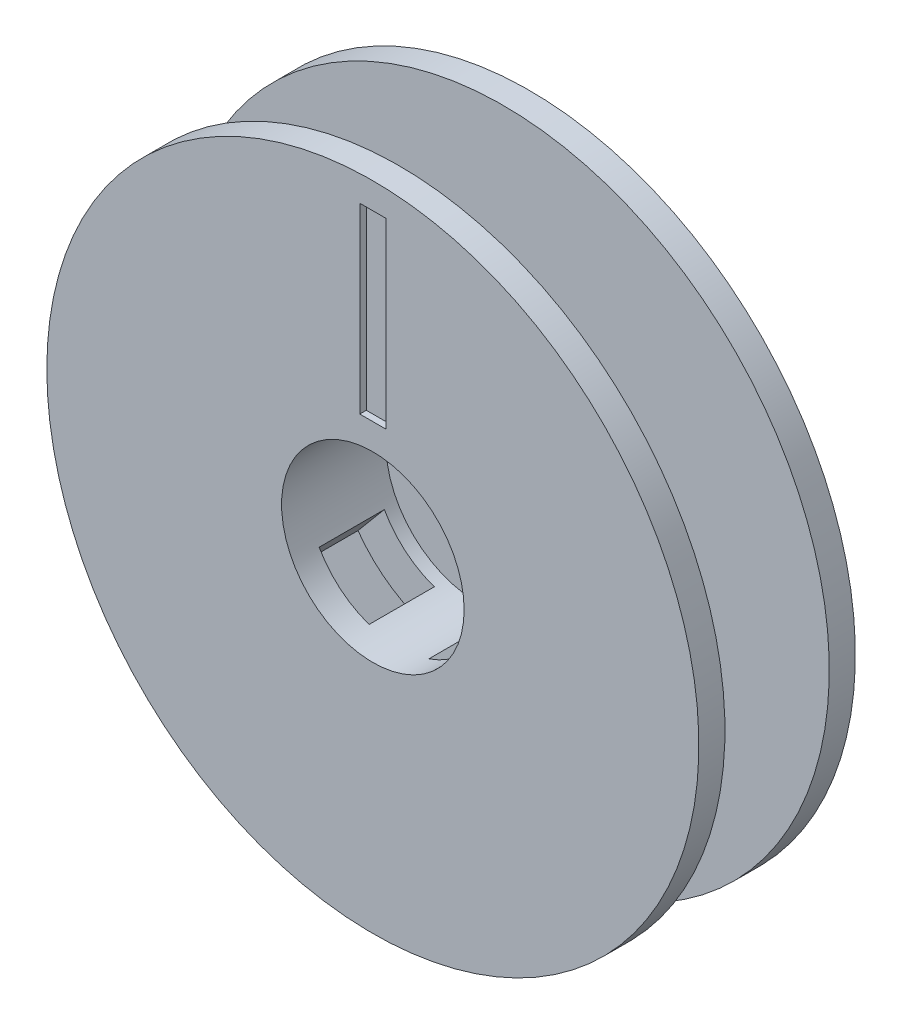
from build123d import *

# Parameters (mm, degrees)
SKETCH_3_R          = 13
EXTRUDE_1_DEPTH     = 5
CUT_EXTRUDE_2_DEPTH = 2.5
SKETCH_6_R          = 2
CUT_EXTRUDE_3_DEPTH = 18
SKETCH_7_R          = 7
CUT_EXTRUDE_4_DEPTH = 8
CUT_EXTRUDE_6_DEPTH = 5
FILLET_1_R          = 1
SKETCH_10_W         = 2
SKETCH_10_H         = 14
CUT_EXTRUDE_7_DEPTH = 0.5


with BuildPart() as part:
    # ｽｹｯﾁ3 → ﾎﾞｽ - 押し出し1 (new body)
    with BuildSketch(Plane.XY):
        Circle(SKETCH_3_R)
    extrude(amount=EXTRUDE_1_DEPTH)

    # ｽｹｯﾁ2 → ｶｯﾄ - 押し出し2 (cut)
    with BuildSketch(Plane.XY):
        with BuildLine():
            Line((3.75, 6.495190528), (2.773808556, 13.582081265))
            ThreePointArc((2.773808556, 13.582081265), (0, 16), (-2.773808556, 13.582081265))
            Line((-2.773808556, 13.582081265), (-3.75, 6.495190528))
            Line((-3.75, 6.495190528), (-10.375523134, 9.193229308))
            ThreePointArc((-10.375523134, 9.193229308), (-13.856406461, 8), (-13.14933169, 4.388851958))
            Line((-13.14933169, 4.388851958), (-7.5, 0))
            Line((-7.5, 0), (-13.14933169, -4.388851958))
            ThreePointArc((-13.14933169, -4.388851958), (-13.856406461, -8), (-10.375523134, -9.193229308))
            Line((-10.375523134, -9.193229308), (-3.75, -6.495190528))
            Line((-3.75, -6.495190528), (-2.773808556, -13.582081265))
            ThreePointArc((-2.773808556, -13.582081265), (0, -16), (2.773808556, -13.582081265))
            Line((2.773808556, -13.582081265), (3.75, -6.495190528))
            Line((3.75, -6.495190528), (10.375523134, -9.193229308))
            ThreePointArc((10.375523134, -9.193229308), (13.856406461, -8), (13.14933169, -4.388851958))
            Line((13.14933169, -4.388851958), (7.5, 0))
            Line((7.5, 0), (13.14933169, 4.388851958))
            ThreePointArc((13.14933169, 4.388851958), (13.856406461, 8), (10.375523134, 9.193229308))
            Line((10.375523134, 9.193229308), (3.75, 6.495190528))
        make_face()
    extrude(amount=CUT_EXTRUDE_2_DEPTH, mode=Mode.SUBTRACT)

    # ｽｹｯﾁ5 → 回転1 (revolve)
    with BuildSketch(Plane(origin=(0, 0, 0), x_dir=(1, 0, 0), z_dir=(0, 1, 0))):
        Polygon((0, -5), (25, -5), (25, -7), (10, -7), (10, -15), (25, -15), (25, -17), (0, -17), align=None)
    revolve(axis=Axis((0, 0, 0), (0, 0, 1)))

    # ｽｹｯﾁ6 → ｶｯﾄ - 押し出し3 (cut, through all)
    with BuildSketch(Plane.XY.offset(17)):
        Circle(SKETCH_6_R)
    extrude(amount=-CUT_EXTRUDE_3_DEPTH, mode=Mode.SUBTRACT)

    # ｽｹｯﾁ7 → ｶｯﾄ - 押し出し4 (cut)
    with BuildSketch(Plane.XY.offset(17)):
        Circle(SKETCH_7_R)
    extrude(amount=-CUT_EXTRUDE_4_DEPTH, mode=Mode.SUBTRACT)

    # ｽｹｯﾁ9 → ｶｯﾄ - 押し出し6 (cut)
    with BuildSketch(Plane(origin=(0, 0, 15), x_dir=(-1, 0, 0), z_dir=(0, 0, -1))):
        Polygon((-3.843473937, -0.691164305), (-11.556925253, -9.883697623), (-7.726703038, -13.097635671), (-0.013251721, -3.905102354), align=None)
    cut_extrude_6 = extrude(amount=CUT_EXTRUDE_6_DEPTH, mode=Mode.SUBTRACT)

    # ﾐﾗｰ1: ｶｯﾄ - 押し出し6 across plane
    add(cut_extrude_6.mirror(Plane(origin=(0, 0, 0), x_dir=(0, 0, 1), z_dir=(1, 0, 0))), mode=Mode.SUBTRACT)

    # ﾌｨﾚｯﾄ1
    fillet_1_edges = [part.edges().sort_by_distance(p)[0] for p in [
        (4.308653161, -9.024162451, 12.5),
        (-4.308653161, -9.024162451, 12.5),
    ]]
    fillet(fillet_1_edges, radius=FILLET_1_R)

    # ｽｹｯﾁ10 → ｶｯﾄ - 押し出し7 (cut)
    with BuildSketch(Plane.XY.offset(17)):
        with Locations((0, 16)):
            Rectangle(SKETCH_10_W, SKETCH_10_H)
    extrude(amount=-CUT_EXTRUDE_7_DEPTH, mode=Mode.SUBTRACT)


solid = part.part
